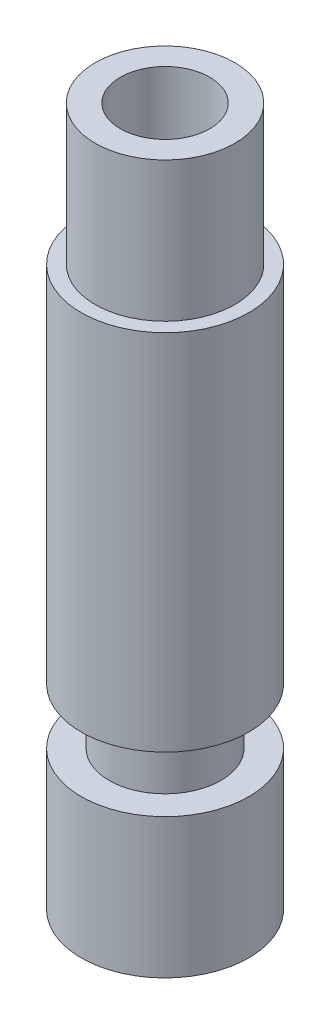
from build123d import *

# Parameters (mm, degrees)
SKETCH2_R          = 1.6
CUT_EXTRUDE1_DEPTH = 26


with BuildPart() as part:
    # Sketch1 → Revolve1 (revolve)
    with BuildSketch(Plane.XY):
        Polygon((0, 0), (0, 25), (2.5, 25), (2.5, 20), (3, 20), (3, 7), (2, 7), (2, 5), (3, 5), (3, 0), align=None)
    revolve(axis=Axis((0, 0, 0), (0, 1, 0)))

    # Sketch2 → Cut-Extrude1 (cut, through all)
    with BuildSketch(Plane(origin=(0, 25, 0), x_dir=(1, 0, 0), z_dir=(0, 1, 0))):
        Circle(SKETCH2_R)
    extrude(amount=-CUT_EXTRUDE1_DEPTH, mode=Mode.SUBTRACT)


solid = part.part
